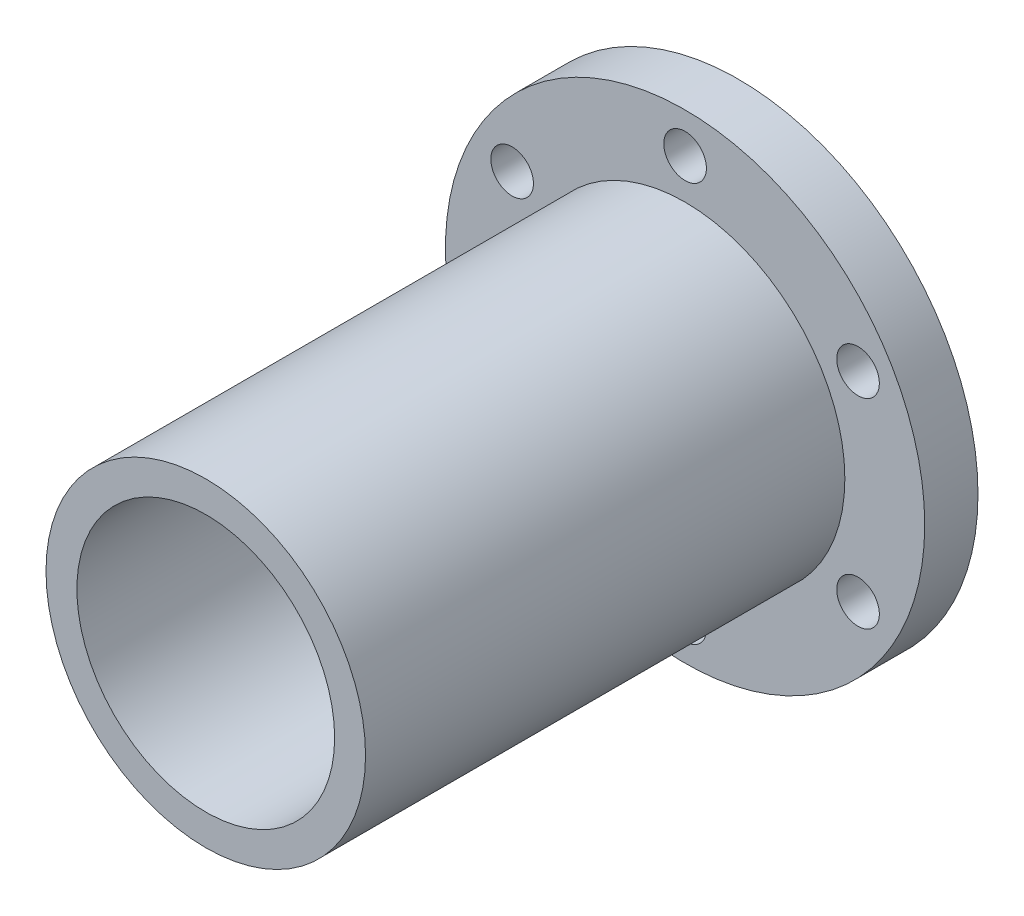
from build123d import *

# Parameters (mm, degrees)
SKETCH1_R           = 22.5
BOSS_EXTRUDE1_DEPTH = 5
SKETCH2_R           = 15
SKETCH2_R_2         = 12.1
BOSS_EXTRUDE2_DEPTH = 45
SKETCH3_R           = 2
CUT_EXTRUDE1_DEPTH  = 5


with BuildPart() as part:
    # Sketch1 → Boss-Extrude1 (new body)
    with BuildSketch(Plane.XY):
        Circle(SKETCH1_R)
    extrude(amount=BOSS_EXTRUDE1_DEPTH)

    # Sketch2 → Boss-Extrude2 (add)
    with BuildSketch(Plane.XY.offset(5)):
        Circle(SKETCH2_R)
        Circle(SKETCH2_R_2, mode=Mode.SUBTRACT)
    extrude(amount=BOSS_EXTRUDE2_DEPTH)

    # Sketch3 → Cut-Extrude1 (cut)
    with BuildSketch(Plane.XY.offset(5)):
        with Locations((0, 18.75)):
            Circle(SKETCH3_R)
        with Locations((16.237976321, 9.375)):
            Circle(SKETCH3_R)
        with Locations((16.237976321, -9.375)):
            Circle(SKETCH3_R)
        with Locations((0, -18.75)):
            Circle(SKETCH3_R)
        with Locations((-16.237976321, -9.375)):
            Circle(SKETCH3_R)
        with Locations((-16.237976321, 9.375)):
            Circle(SKETCH3_R)
    extrude(amount=-CUT_EXTRUDE1_DEPTH, mode=Mode.SUBTRACT)


solid = part.part
